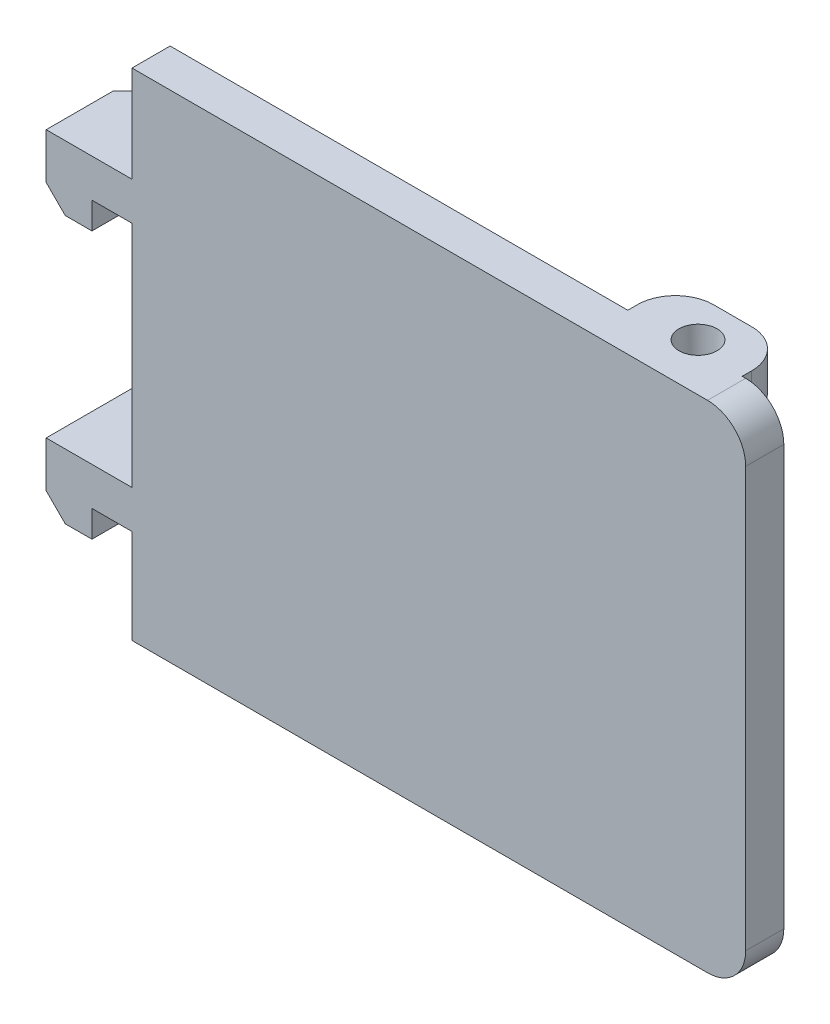
from build123d import *

# Parameters (mm, degrees)
SKETCH_2_W          = 32.183544672
SKETCH_2_H          = 26
EXTRUDE_1_DEPTH     = 2
FILLET_1_R          = 2
SKETCH_5_W          = 6
SKETCH_5_H          = 2
EXTRUDE_2_DEPTH     = 2.5
FILLET_2_R          = 2
SKETCH_6_R          = 1
CUT_EXTRUDE_3_DEPTH = 4
CUT_EXTRUDE_3_TAPER = 2
SKETCH_7_R          = 1
CUT_EXTRUDE_4_DEPTH = 4
CUT_EXTRUDE_4_TAPER = 2
SKETCH_9_W          = 4.5
SKETCH_9_H          = 2
EXTRUDE_3_DEPTH     = 2
SKETCH_10_W         = 2.4
SKETCH_10_H         = 1.4
EXTRUDE_4_DEPTH     = 2
CHAMFER_1_SIZE      = 1
SKETCH_11_W         = 8.5
SKETCH_11_H         = 2
EXTRUDE_5_DEPTH     = 2.5
CHAMFER_2_SIZE      = 1


with BuildPart() as part:
    # 草图2 → 凸台-拉伸1 (new body)
    with BuildSketch(Plane.XY):
        with Locations((-0.901029093, -19.434236018)):
            Rectangle(SKETCH_2_W, SKETCH_2_H)
    extrude(amount=EXTRUDE_1_DEPTH)

    # 圆角1
    fillet_1_edges = [part.edges().sort_by_distance(p)[0] for p in [
        (15.190743243, -32.434236018, 1),
        (15.190743243, -6.434236018, 1),
    ]]
    fillet(fillet_1_edges, radius=FILLET_1_R)

    # 草图5 → 凸台-拉伸2 (add)
    with BuildSketch(Plane(origin=(0, 0, 0), x_dir=(-1, 0, 0), z_dir=(0, 0, -1))):
        with Locations((-10.007198571, -7.434236018)):
            Rectangle(SKETCH_5_W, SKETCH_5_H)
        with Locations((-10.007198571, -31.434236018)):
            Rectangle(SKETCH_5_W, SKETCH_5_H)
    extrude(amount=EXTRUDE_2_DEPTH)

    # 圆角2
    fillet_2_edges = [part.edges().sort_by_distance(p)[0] for p in [
        (13.007198571, -7.434236018, -2.5),
        (7.007198571, -7.434236018, -2.5),
        (13.007198571, -31.434236018, -2.5),
        (7.007198571, -31.434236018, -2.5),
    ]]
    fillet(fillet_2_edges, radius=FILLET_2_R)

    # 草图6 → 切除-拉伸3 (cut)
    with BuildSketch(Plane.XZ.offset(32.434236018)):
        with Locations((10.190743244, -0.5)):
            Circle(SKETCH_6_R)
    extrude(amount=-CUT_EXTRUDE_3_DEPTH, taper=CUT_EXTRUDE_3_TAPER, mode=Mode.SUBTRACT)

    # 草图7 → 切除-拉伸4 (cut)
    with BuildSketch(Plane(origin=(0, -6.434236018, 0), x_dir=(1, 0, 0), z_dir=(0, 1, 0))):
        with Locations((10.190743243, 0.5)):
            Circle(SKETCH_7_R)
    extrude(amount=-CUT_EXTRUDE_4_DEPTH, taper=CUT_EXTRUDE_4_TAPER, mode=Mode.SUBTRACT)

    # 草图9 → 凸台-拉伸3 (add)
    with BuildSketch(Plane(origin=(0, 0, 0), x_dir=(-1, 0, 0), z_dir=(0, 0, -1))):
        with Locations((19.242801429, -12.484236018)):
            Rectangle(SKETCH_9_W, SKETCH_9_H)
        with Locations((19.242801429, -26.484236018)):
            Rectangle(SKETCH_9_W, SKETCH_9_H)
    extrude(amount=-EXTRUDE_3_DEPTH)

    # 草图10 → 凸台-拉伸4 (add)
    with BuildSketch(Plane(origin=(0, 0, 0), x_dir=(-1, 0, 0), z_dir=(0, 0, -1))):
        with Locations((20.292801429, -14.184236018)):
            Rectangle(SKETCH_10_W, SKETCH_10_H)
        with Locations((20.292801429, -28.184236018)):
            Rectangle(SKETCH_10_W, SKETCH_10_H)
    extrude(amount=-EXTRUDE_4_DEPTH)

    # 倒角1
    chamfer_1_edges = [part.edges().sort_by_distance(p)[0] for p in [
        (-21.492801429, -14.884236018, 1),
        (-21.492801429, -28.884236018, 1),
    ]]
    chamfer(chamfer_1_edges, length=CHAMFER_1_SIZE)

    # 草图11 → 凸台-拉伸5 (add)
    with BuildSketch(Plane(origin=(0, 0, 0), x_dir=(-1, 0, 0), z_dir=(0, 0, -1))):
        with Locations((17.242801429, -12.484236018)):
            Rectangle(SKETCH_11_W, SKETCH_11_H)
        with Locations((17.242801429, -26.484236018)):
            Rectangle(SKETCH_11_W, SKETCH_11_H)
    extrude(amount=EXTRUDE_5_DEPTH)

    # 倒角2
    chamfer_2_edges = [part.edges().sort_by_distance(p)[0] for p in [
        (-21.492801429, -12.484236018, -2.5),
        (-12.992801429, -12.484236018, -2.5),
        (-12.992801429, -26.484236018, -2.5),
    ]]
    chamfer(chamfer_2_edges, length=CHAMFER_2_SIZE)


solid = part.part
